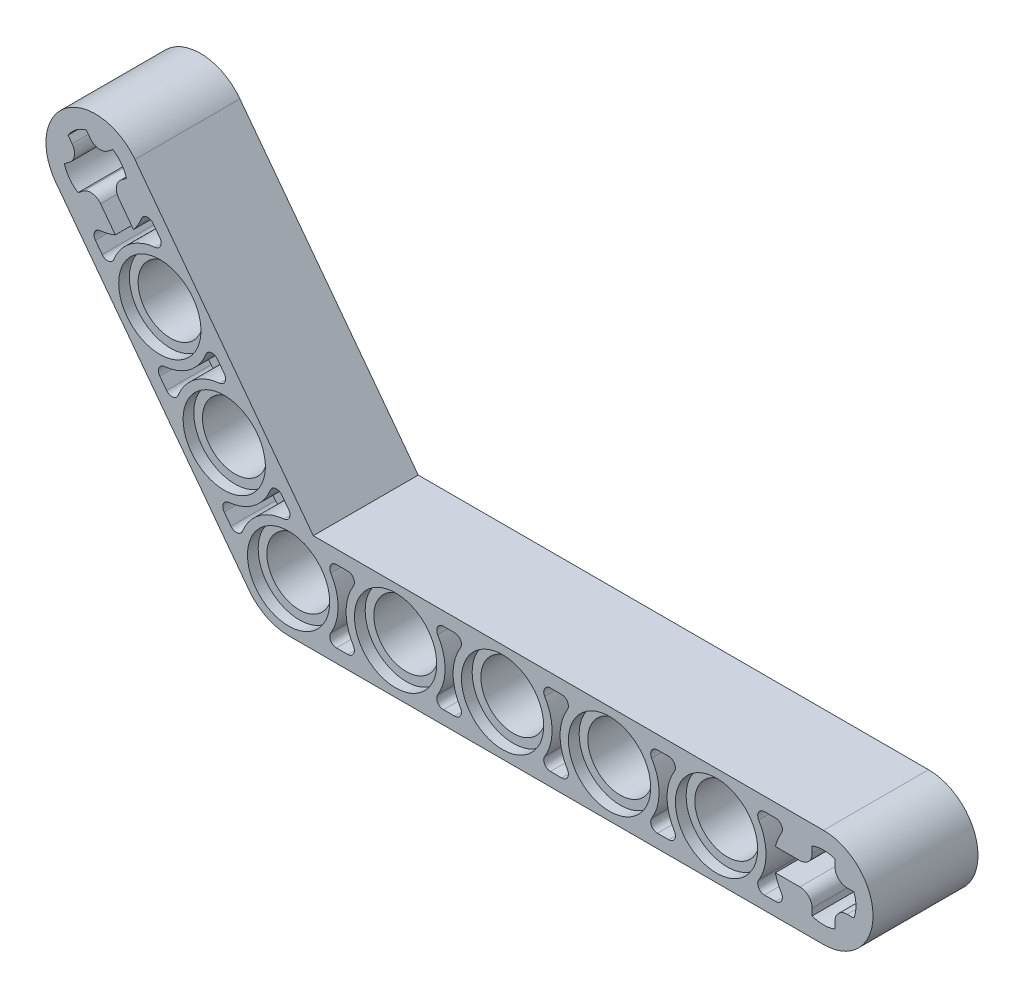
from build123d import *

# Parameters (mm, degrees)
BOSS_EXTRUDE1_DEPTH = 3.925
BOSS_EXTRUDE2_DEPTH = 0.6
BOSS_EXTRUDE4_DEPTH = 7.85
BOSS_EXTRUDE5_DEPTH = 1.2
LPATTERN1_COUNT     = 5
LPATTERN1_PITCH     = 8
CUT_EXTRUDE1_DEPTH  = 8.85
LPATTERN2_COUNT     = 3
LPATTERN2_PITCH     = 8
CUT_EXTRUDE2_DEPTH  = 8.85


with BuildPart() as part:
    # Sketch2 → Boss-Extrude1 (new body, symmetric)
    with BuildSketch(Plane.XY):
        with BuildLine():
            Line((0, -3.7), (8, -3.7))
            ThreePointArc((8, -3.7), (11.7, 0), (8, 3.7))
            Line((8, 3.7), (0, 3.7))
            ThreePointArc((0, 3.7), (-3.7, 0), (0, -3.7))
        make_face()
        with BuildLine():
            Line((3.577708764, 2.7), (4.422291236, 2.7))
            ThreePointArc((4.422291236, 2.7), (4.858727016, 2.443975018), (4.848208946, 1.938095238))
            ThreePointArc((4.848208946, 1.938095238), (4.3, 0), (4.848208946, -1.938095238))
            ThreePointArc((4.848208946, -1.938095238), (4.858727016, -2.443975018), (4.422291236, -2.7))
            Line((4.422291236, -2.7), (3.577708764, -2.7))
            ThreePointArc((3.577708764, -2.7), (3.141272984, -2.443975018), (3.151791054, -1.938095238))
            ThreePointArc((3.151791054, -1.938095238), (3.7, 0), (3.151791054, 1.938095238))
            ThreePointArc((3.151791054, 1.938095238), (3.141272984, 2.443975018), (3.577708764, 2.7))
        make_face(mode=Mode.SUBTRACT)
    boss_extrude1 = extrude(amount=BOSS_EXTRUDE1_DEPTH, both=True)

    # Sketch3 → Boss-Extrude2 (add, symmetric)
    with BuildSketch(Plane.XY):
        with BuildLine():
            Line((3.577708764, -2.7), (4.422291236, -2.7))
            ThreePointArc((4.422291236, -2.7), (4.858727016, -2.443975018), (4.848208946, -1.938095238))
            ThreePointArc((4.848208946, -1.938095238), (4.3, 0), (4.848208946, 1.938095238))
            ThreePointArc((4.848208946, 1.938095238), (4.858727016, 2.443975018), (4.422291236, 2.7))
            Line((4.422291236, 2.7), (3.577708764, 2.7))
            ThreePointArc((3.577708764, 2.7), (3.141272984, 2.443975018), (3.151791054, 1.938095238))
            ThreePointArc((3.151791054, 1.938095238), (3.7, 0), (3.151791054, -1.938095238))
            ThreePointArc((3.151791054, -1.938095238), (3.141272984, -2.443975018), (3.577708764, -2.7))
        make_face()
    boss_extrude2 = extrude(amount=BOSS_EXTRUDE2_DEPTH, both=True)

    # Sketch6 → Boss-Extrude4 (add)
    with BuildSketch(Plane.XY.offset(3.925)):
        with BuildLine():
            Line((-1.859568798, 8.615799666), (2.954951387, 2.226715586))
            ThreePointArc((2.954951387, 2.226715586), (2.226715586, -2.954951387), (-2.954951387, -2.226715586))
            Line((-2.954951387, -2.226715586), (-7.769471572, 4.162368495))
            ThreePointArc((-7.769471572, 4.162368495), (-7.041235771, 9.344035468), (-1.859568798, 8.615799666))
        make_face()
        with BuildLine():
            Line((-0.505085425, 5.156699379), (0.003196994, 4.482185826))
            ThreePointArc((0.003196994, 4.482185826), (0.061379962, 3.979553034), (-0.348963527, 3.683507087))
            ThreePointArc((-0.348963527, 3.683507087), (-2.226715586, 2.954951387), (-3.444626885, 1.350757425))
            ThreePointArc((-3.444626885, 1.350757425), (-3.842310509, 1.037911269), (-4.30943476, 1.232384701))
            Line((-4.30943476, 1.232384701), (-4.81771718, 1.906898254))
            ThreePointArc((-4.81771718, 1.906898254), (-4.875900147, 2.409531047), (-4.465556658, 2.705576994))
            ThreePointArc((-4.465556658, 2.705576994), (-2.5878046, 3.434132693), (-1.3698933, 5.038326655))
            ThreePointArc((-1.3698933, 5.038326655), (-0.972209677, 5.351172811), (-0.505085425, 5.156699379))
        make_face(mode=Mode.SUBTRACT)
    boss_extrude4 = extrude(amount=-BOSS_EXTRUDE4_DEPTH)

    # Sketch7 → Boss-Extrude5 (add)
    with BuildSketch(Plane.XY.offset(0.6)):
        with BuildLine():
            Line((-0.505085425, 5.156699379), (0.003196994, 4.482185826))
            ThreePointArc((0.003196994, 4.482185826), (0.061379962, 3.979553034), (-0.348963527, 3.683507087))
            ThreePointArc((-0.348963527, 3.683507087), (-2.226715586, 2.954951387), (-3.444626885, 1.350757425))
            ThreePointArc((-3.444626885, 1.350757425), (-3.842310509, 1.037911269), (-4.30943476, 1.232384701))
            Line((-4.30943476, 1.232384701), (-4.81771718, 1.906898254))
            ThreePointArc((-4.81771718, 1.906898254), (-4.875900147, 2.409531047), (-4.465556658, 2.705576994))
            ThreePointArc((-4.465556658, 2.705576994), (-2.5878046, 3.434132693), (-1.3698933, 5.038326655))
            ThreePointArc((-1.3698933, 5.038326655), (-0.972209677, 5.351172811), (-0.505085425, 5.156699379))
        make_face()
    boss_extrude5 = extrude(amount=-BOSS_EXTRUDE5_DEPTH)

    # Sketch1 → Cut-Revolve1 (revolve, cut)
    with BuildSketch(Plane(origin=(0, 0, 0), x_dir=(1, 0, 0), z_dir=(0, 1, 0))):
        Polygon((0, 3.925), (0, -3.925), (-3.075, -3.925), (-3.075, -3.125), (-2.425, -3.125), (-2.425, 3.125), (-3.075, 3.125), (-3.075, 3.925), align=None)
    cut_revolve1 = revolve(axis=Axis((0, 0, -3.925), (0, 0, 1)), mode=Mode.SUBTRACT)

    # LPattern1: Boss-Extrude1, Boss-Extrude2, Cut-Revolve1 ×5
    with Locations(*[(i * LPATTERN1_PITCH, 0, 0) for i in range(1, LPATTERN1_COUNT)]):
        add(boss_extrude1)
        add(boss_extrude2)
        add(cut_revolve1, mode=Mode.SUBTRACT)

    # Sketch8 → Cut-Extrude1 (cut, through all)
    with BuildSketch(Plane.XY.offset(3.925)):
        with BuildLine():
            Line((40.85, 2.271150589), (40.85, 1.774446968))
            ThreePointArc((40.85, 1.774446968), (41.120764248, 1.120764248), (41.774446968, 0.85))
            Line((41.774446968, 0.85), (42.271150589, 0.85))
            ThreePointArc((42.271150589, 0.85), (42.425, 0), (42.271150589, -0.85))
            Line((42.271150589, -0.85), (41.774446968, -0.85))
            ThreePointArc((41.774446968, -0.85), (41.120764248, -1.120764248), (40.85, -1.774446968))
            Line((40.85, -1.774446968), (40.85, -2.271150589))
            ThreePointArc((40.85, -2.271150589), (40, -2.425), (39.15, -2.271150589))
            Line((39.15, -2.271150589), (39.15, -1.774446968))
            ThreePointArc((39.15, -1.774446968), (38.879235752, -1.120764248), (38.225553032, -0.85))
            Line((38.225553032, -0.85), (36.398958484, -0.85))
            ThreePointArc((36.398958484, -0.85), (36.580032933, -1.412028774), (36.848208946, -1.938095238))
            ThreePointArc((36.848208946, -1.938095238), (36.858727016, -2.443975018), (36.422291236, -2.7))
            Line((36.422291236, -2.7), (35.577708764, -2.7))
            ThreePointArc((35.577708764, -2.7), (35.141272984, -2.443975018), (35.151791054, -1.938095238))
            ThreePointArc((35.151791054, -1.938095238), (35.7, 0), (35.151791054, 1.938095238))
            ThreePointArc((35.151791054, 1.938095238), (35.141272984, 2.443975018), (35.577708764, 2.7))
            Line((35.577708764, 2.7), (36.422291236, 2.7))
            ThreePointArc((36.422291236, 2.7), (36.858727016, 2.443975018), (36.848208946, 1.938095238))
            ThreePointArc((36.848208946, 1.938095238), (36.580032933, 1.412028774), (36.398958484, 0.85))
            Line((36.398958484, 0.85), (38.225553032, 0.85))
            ThreePointArc((38.225553032, 0.85), (38.879235752, 1.120764248), (39.15, 1.774446968))
            Line((39.15, 1.774446968), (39.15, 2.271150589))
            ThreePointArc((39.15, 2.271150589), (40, 2.425), (40.85, 2.271150589))
        make_face()
    extrude(amount=-CUT_EXTRUDE1_DEPTH, mode=Mode.SUBTRACT)

    # LPattern2: Boss-Extrude4, Boss-Extrude5, Cut-Revolve1 ×3
    with Locations(*[Vector(-0.601815023, 0.79863551, 0) * (i * LPATTERN2_PITCH) for i in range(1, LPATTERN2_COUNT)]):
        add(boss_extrude4)
        add(boss_extrude5)
        add(cut_revolve1, mode=Mode.SUBTRACT)

    # Sketch9 → Cut-Extrude2 (cut, through all)
    with BuildSketch(Plane.XY.offset(3.925)):
        with BuildLine():
            Line((-16.768924835, 18.47927988), (-16.372239685, 18.778203581))
            ThreePointArc((-16.372239685, 18.778203581), (-16.013135445, 19.387841606), (-16.190289583, 20.072845831))
            Line((-16.190289583, 20.072845831), (-16.489213284, 20.469530981))
            ThreePointArc((-16.489213284, 20.469530981), (-15.902961987, 21.103943353), (-15.131532917, 21.49261652))
            Line((-15.131532917, 21.49261652), (-14.832609215, 21.09593137))
            ThreePointArc((-14.832609215, 21.09593137), (-14.222971191, 20.73682713), (-13.537966966, 20.913981268))
            Line((-13.537966966, 20.913981268), (-13.141281816, 21.212904969))
            ThreePointArc((-13.141281816, 21.212904969), (-12.506869444, 20.626653672), (-12.118196277, 19.855224602))
            Line((-12.118196277, 19.855224602), (-12.514881426, 19.556300901))
            ThreePointArc((-12.514881426, 19.556300901), (-12.873985667, 18.946662876), (-12.696831529, 18.261658651))
            Line((-12.696831529, 18.261658651), (-11.597559489, 16.802875383))
            ThreePointArc((-11.597559489, 16.802875383), (-11.257676676, 17.285725227), (-10.998933671, 17.816494816))
            ThreePointArc((-10.998933671, 17.816494816), (-10.601250047, 18.129340972), (-10.134125796, 17.93486754))
            Line((-10.134125796, 17.93486754), (-9.625843376, 17.260353987))
            ThreePointArc((-9.625843376, 17.260353987), (-9.567660409, 16.757721194), (-9.978003898, 16.461675247))
            ThreePointArc((-9.978003898, 16.461675247), (-11.855755956, 15.733119548), (-13.073667256, 14.128925586))
            ThreePointArc((-13.073667256, 14.128925586), (-13.471350879, 13.81607943), (-13.93847513, 14.010552862))
            Line((-13.93847513, 14.010552862), (-14.44675755, 14.685066415))
            ThreePointArc((-14.44675755, 14.685066415), (-14.504940518, 15.187699208), (-14.094597029, 15.483745155))
            ThreePointArc((-14.094597029, 15.483745155), (-13.513069316, 15.586164969), (-12.955239856, 15.779789844))
            Line((-12.955239856, 15.779789844), (-14.054511896, 17.238573112))
            ThreePointArc((-14.054511896, 17.238573112), (-14.664149921, 17.597677352), (-15.349154146, 17.420523214))
            Line((-15.349154146, 17.420523214), (-15.745839295, 17.121599513))
            ThreePointArc((-15.745839295, 17.121599513), (-16.380251668, 17.70785081), (-16.768924835, 18.47927988))
        make_face()
    extrude(amount=-CUT_EXTRUDE2_DEPTH, mode=Mode.SUBTRACT)


solid = part.part
